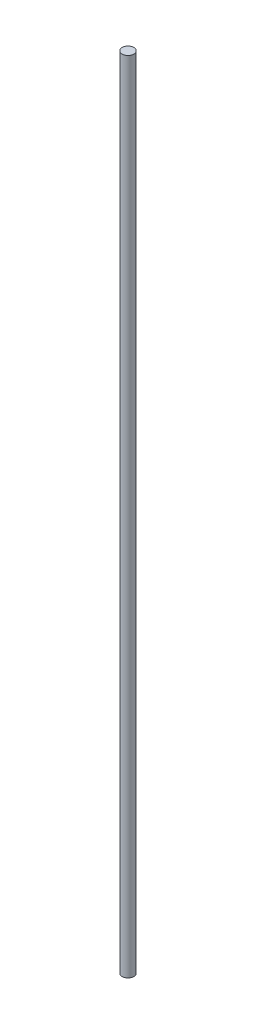
from build123d import *

# Parameters (mm, degrees)
ESQUISSE1_R        = 1.5
BOSS_EXTRU_1_DEPTH = 205.8


with BuildPart() as part:
    # Esquisse1 → Boss.-Extru.1 (new body)
    with BuildSketch(Plane(origin=(0, 0, 0), x_dir=(1, 0, 0), z_dir=(0, 1, 0))):
        Circle(ESQUISSE1_R)
    extrude(amount=BOSS_EXTRU_1_DEPTH)


solid = part.part
